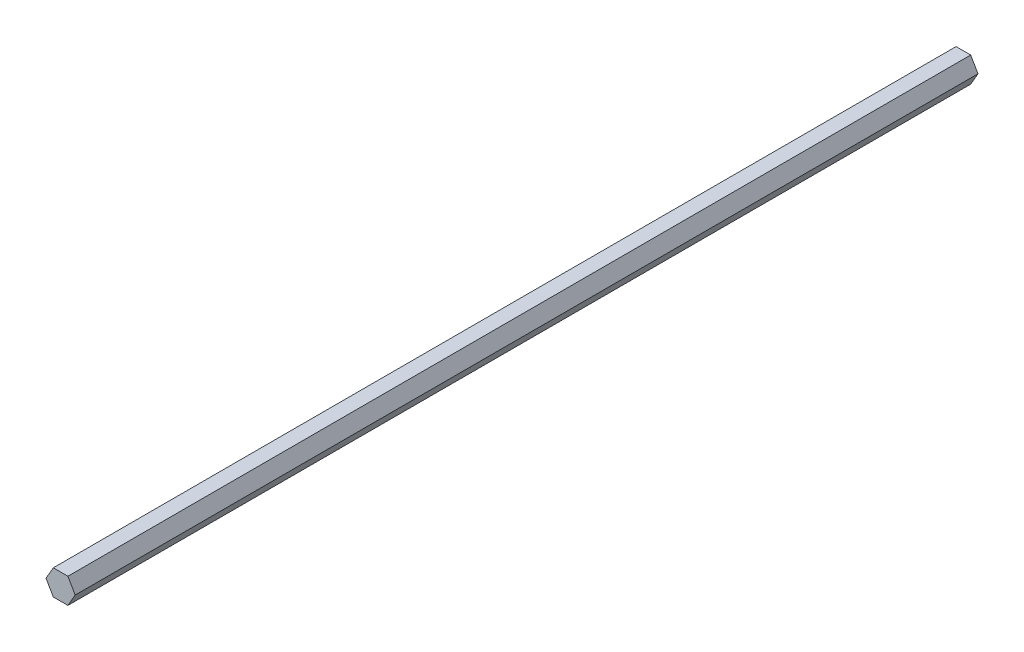
from build123d import *

# Parameters (mm, degrees)
BOSS_EXTRUDE1_DEPTH = 453.18


with BuildPart() as part:
    # Sketch1 → Boss-Extrude1 (new body)
    with BuildSketch(Plane.XY):
        Polygon((-3.665, 6.34796621), (-7.33, 0), (-3.665, -6.34796621), (3.665, -6.34796621), (7.33, 0), (3.665, 6.34796621), align=None)
    extrude(amount=BOSS_EXTRUDE1_DEPTH)


solid = part.part
